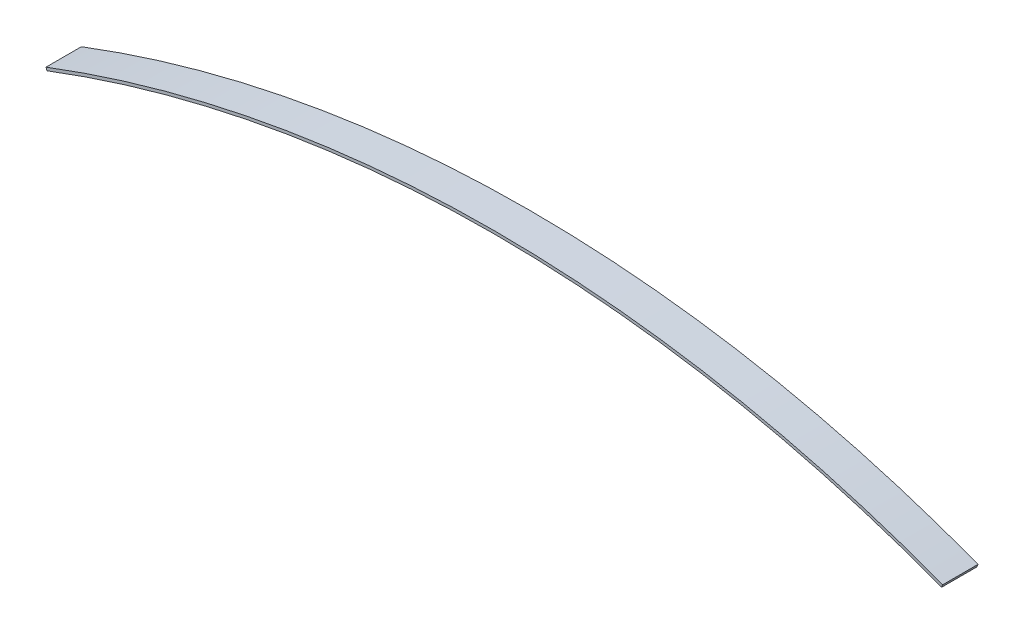
from build123d import *

# Parameters (mm, degrees)
SKETCH2_W = 6.4
SKETCH2_H = 79


with BuildPart() as part:
    # Sweep1: sweep along a path in Sketch1
    with BuildLine(Plane.XY) as sweep1_path:
        ThreePointArc((-1000, 2624.833962881), (0, 2808.870472751), (1000, 2624.833962881))
    # Sketch2 → Sweep1 (sweep)
    with BuildSketch(Plane(origin=(0, 0, 0), x_dir=(0.356014992, -0.934480243, 0), z_dir=(-0.934480243, -0.356014992, 0))):
        with Locations((-2809, 0)):
            Rectangle(SKETCH2_W, SKETCH2_H)
    sweep(path=sweep1_path.line)


solid = part.part
